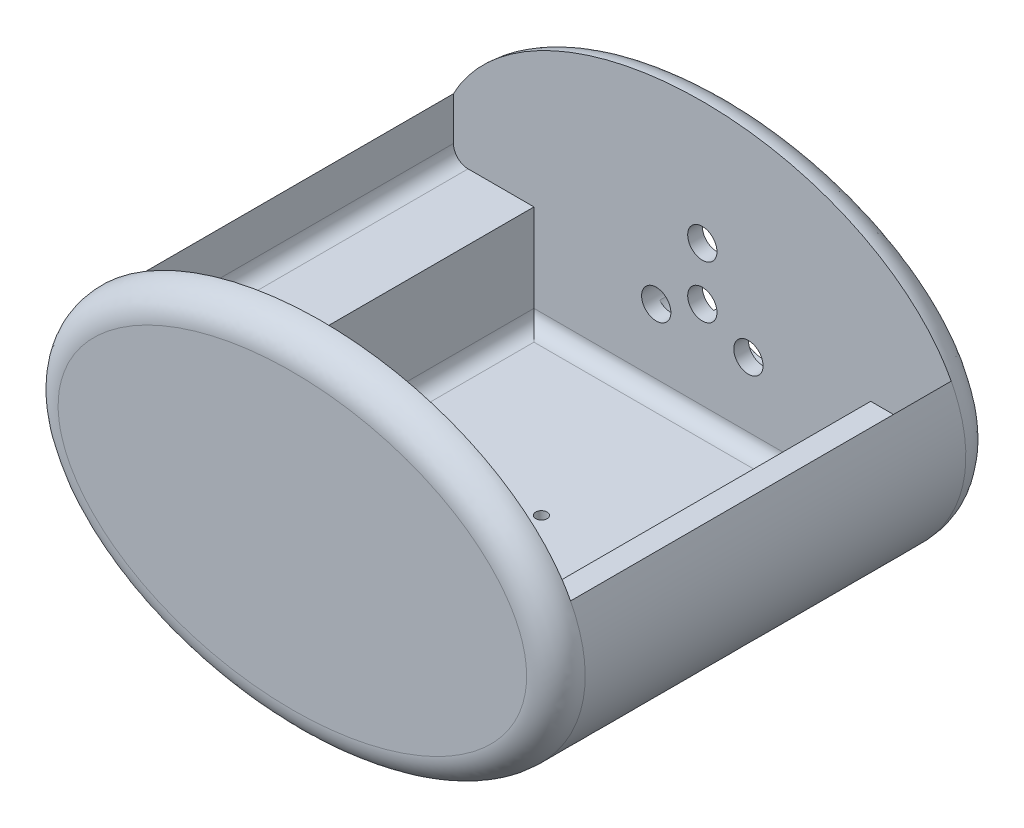
from build123d import *

# Parameters (mm, degrees)
SKETCH1_RX               = 22.86
SKETCH1_RY               = 15.24
BOSS_EXTRUDE4_DEPTH      = 45.72
CUT_EXTRUDE2_START       = -10.16
SKETCH4_W                = 29.21
SKETCH4_H                = 17.78
CUT_EXTRUDE2_DEPTH       = 33.02
SKETCH7_W                = 14.643913221
SKETCH7_H                = 35.56
CUT_EXTRUDE4_DEPTH       = 33.02
CUT_EXTRUDE4_DEPTH_BACK  = 33.02
SKETCH8_R                = 1.27
CUT_EXTRUDE5_DEPTH       = 2.54
FILLET1_R                = 2.54
FILLET2_R                = 2.54
CUT_EXTRUDE11_START      = -2.54
SKETCH12_W               = 43.18
SKETCH12_H               = 19.05
CUT_EXTRUDE11_DEPTH      = 33.02
FILLET3_R                = 1.27
CUT_EXTRUDE13_START      = -2.54
SKETCH13_W               = 5.08
SKETCH13_H               = 5.08
CUT_EXTRUDE13_DEPTH      = 4.8100001
SKETCH14_R               = 0.5
CUT_EXTRUDE14_DEPTH      = 4.8100001
CUT_EXTRUDE14_DEPTH_BACK = 27.6700001
SKETCH16_R               = 2.54
CUT_EXTRUDE15_DEPTH      = 1.27
FILLET4_R                = 1.27


with BuildPart() as part:
    # Sketch1 → Boss-Extrude4 (new body)
    with BuildSketch(Plane.XY):
        with Locations(Location((0, 0), (0, 0, 180))):
            Ellipse(SKETCH1_RX, SKETCH1_RY)
    extrude(amount=BOSS_EXTRUDE4_DEPTH)

    # Sketch4 → Cut-Extrude2 (cut)
    with BuildSketch(Plane.XY.offset(45.72).offset(CUT_EXTRUDE2_START)):
        Rectangle(SKETCH4_W, SKETCH4_H)
    extrude(amount=-CUT_EXTRUDE2_DEPTH, mode=Mode.SUBTRACT)

    # Sketch7 → Cut-Extrude4 (cut, two sides)
    with BuildSketch(Plane(origin=(0, 0, 0), x_dir=(0, 0, -1), z_dir=(1, 0, 0))) as cut_extrude4_sk:
        with Locations((-45.421956611, -1.677648267)):
            Rectangle(SKETCH7_W, SKETCH7_H)
    extrude(amount=CUT_EXTRUDE4_DEPTH, mode=Mode.SUBTRACT)
    extrude(cut_extrude4_sk.sketch, amount=-CUT_EXTRUDE4_DEPTH_BACK, mode=Mode.SUBTRACT)

    # Sketch8 → Cut-Extrude5 (cut)
    with BuildSketch(Plane.XY):
        Circle(SKETCH8_R)
        with Locations((3.998447315, -1.999223657)):
            Circle(SKETCH8_R)
        with Locations((-3.998447315, -1.999223657)):
            Circle(SKETCH8_R)
        with Locations((0, 4.572)):
            Circle(SKETCH8_R)
    extrude(amount=CUT_EXTRUDE5_DEPTH, mode=Mode.SUBTRACT)

    # Fillet1
    fillet1_edges = [part.edges().sort_by_distance(p)[0] for p in [
        (22.859987041, 0.016227247, 0),
    ]]
    fillet(fillet1_edges, radius=FILLET1_R)

    # Fillet2
    fillet2_edges = [part.edges().sort_by_distance(p)[0] for p in [
        (22.860000074, 1.7e-08, 38.1),
    ]]
    fillet(fillet2_edges, radius=FILLET2_R)

    # Sketch12 → Cut-Extrude11 (cut)
    with BuildSketch(Plane(origin=(0, 0, 0), x_dir=(-1, 0, 0), z_dir=(0, 0, -1)).offset(CUT_EXTRUDE11_START)):
        with Locations((0, 9.525)):
            Rectangle(SKETCH12_W, SKETCH12_H)
    extrude(amount=-CUT_EXTRUDE11_DEPTH, mode=Mode.SUBTRACT)

    # Fillet3
    fillet3_edges = [part.edges().sort_by_distance(p)[0] for p in [
        (14.605, -8.89, 19.05),
        (0, -8.89, 35.56),
        (-14.605, -8.89, 19.05),
        (0, -8.89, 2.54),
    ]]
    fillet(fillet3_edges, radius=FILLET3_R)

    # Sketch13 → Cut-Extrude13 (cut, through all)
    with BuildSketch(Plane(origin=(0, -8.89, 0), x_dir=(1, 0, 0), z_dir=(0, 1, 0)).offset(CUT_EXTRUDE13_START)):
        with Locations((0, -18.288)):
            Rectangle(SKETCH13_W, SKETCH13_H)
    extrude(amount=-CUT_EXTRUDE13_DEPTH, mode=Mode.SUBTRACT)

    # Sketch14 → Cut-Extrude14 (cut, two sides)
    with BuildSketch(Plane.XZ.offset(11.43)) as cut_extrude14_sk:
        with Locations((0, 20.077999976)):
            Circle(SKETCH14_R)
        with Locations((0, 16.498)):
            Circle(SKETCH14_R)
    extrude(amount=CUT_EXTRUDE14_DEPTH, mode=Mode.SUBTRACT)
    extrude(cut_extrude14_sk.sketch, amount=-CUT_EXTRUDE14_DEPTH_BACK, mode=Mode.SUBTRACT)

    # Sketch16 → Cut-Extrude15 (cut)
    with BuildSketch(Plane(origin=(0, 0, 0), x_dir=(-1, 0, 0), z_dir=(0, 0, -1))):
        with Locations((2.7942426, -1.505997915)):
            Circle(SKETCH16_R)
        with Locations((0.000242604, 3.333352043)):
            Circle(SKETCH16_R)
        with Locations((-2.793757393, -1.505997915)):
            Circle(SKETCH16_R)
    extrude(amount=-CUT_EXTRUDE15_DEPTH, mode=Mode.SUBTRACT)

    # Fillet4
    fillet4_edges = [part.edges().sort_by_distance(p)[0] for p in [
        (-21.59, 0, 19.05),
        (21.59, 0, 19.05),
    ]]
    fillet(fillet4_edges, radius=FILLET4_R)


solid = part.part
